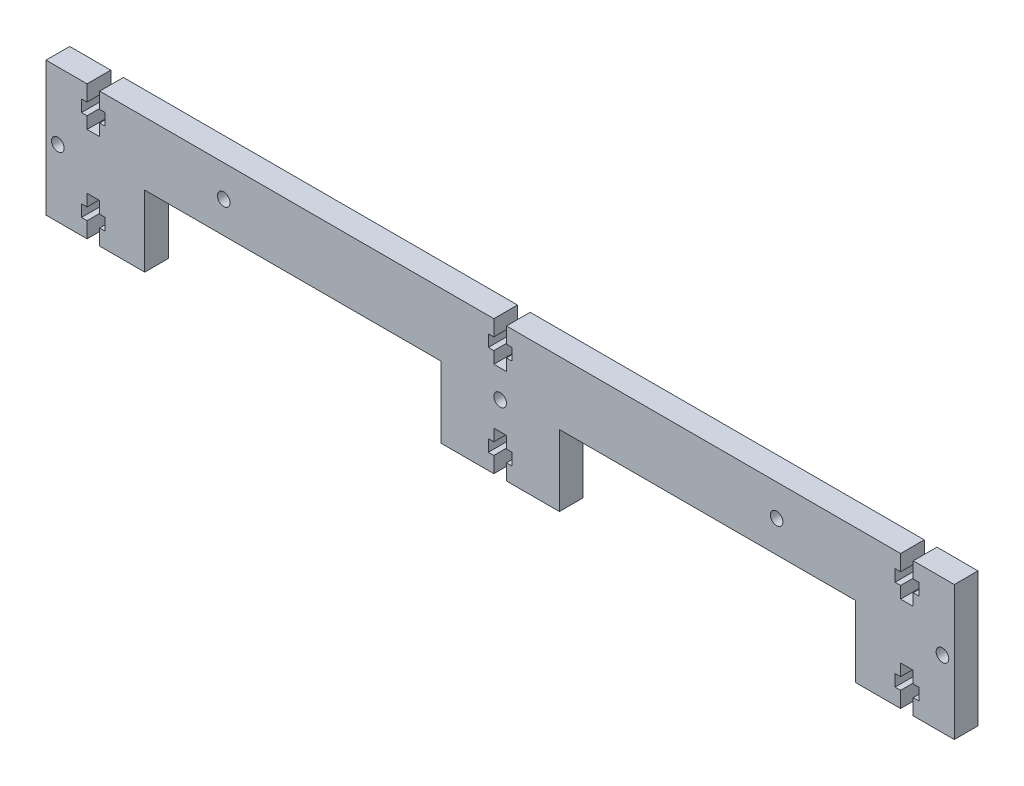
from build123d import *

# Parameters (mm, degrees)
ESBO_O1_R                = 1.6
RESSALTO_EXTRUS_O1_DEPTH = 6
ESBO_O2_R                = 1.6
ESBO_O2_W                = 75
ESBO_O2_H                = 18
CORTE_EXTRUS_O1_DEPTH    = 10


with BuildPart() as part:
    # Esboço1 → Ressalto-extrusão1 (new body)
    with BuildSketch(Plane.XY):
        Polygon((-115, 17), (-115, -17), (-104.6, -17), (-104.6, -13), (-106, -13), (-106, -10), (-104.6, -10), (-104.6, -7), (-101.4, -7), (-101.4, -10), (-100, -10), (-100, -13), (-101.4, -13), (-101.4, -17), (-1.6, -17), (-1.6, -13), (-3, -13), (-3, -10), (-1.6, -10), (-1.6, -7), (1.6, -7), (1.6, -10), (3, -10), (3, -13), (1.6, -13), (1.6, -17), (101.4, -17), (101.4, -13), (100, -13), (100, -10), (101.4, -10), (101.4, -7), (104.6, -7), (104.6, -10), (106, -10), (106, -13), (104.6, -13), (104.6, -17), (115, -17), (115, 17), (104.6, 17), (104.6, 13), (106, 13), (106, 10), (104.6, 10), (104.6, 7), (101.4, 7), (101.4, 10), (100, 10), (100, 13), (101.4, 13), (101.4, 17), (1.6, 17), (1.6, 13), (3, 13), (3, 10), (1.6, 10), (1.6, 7), (-1.6, 7), (-1.6, 10), (-3, 10), (-3, 13), (-1.6, 13), (-1.6, 17), (-101.4, 17), (-101.4, 13), (-100, 13), (-100, 10), (-101.4, 10), (-101.4, 7), (-104.6, 7), (-104.6, 10), (-106, 10), (-106, 13), (-104.6, 13), (-104.6, 17), align=None)
        with Locations((112, 0)):
            Circle(ESBO_O1_R, mode=Mode.SUBTRACT)
        Circle(ESBO_O1_R, mode=Mode.SUBTRACT)
        with Locations((-112, 0)):
            Circle(ESBO_O1_R, mode=Mode.SUBTRACT)
    extrude(amount=RESSALTO_EXTRUS_O1_DEPTH)

    # Esboço2 → Corte-extrusão1 (cut)
    with BuildSketch(Plane.XY.offset(6)):
        with Locations((70, 9)):
            Circle(ESBO_O2_R)
        with Locations((-70, 9)):
            Circle(ESBO_O2_R)
        with Locations((52.5, -8)):
            Rectangle(ESBO_O2_W, ESBO_O2_H)
        with Locations((-52.5, -8)):
            Rectangle(ESBO_O2_W, ESBO_O2_H)
    extrude(amount=-CORTE_EXTRUS_O1_DEPTH, mode=Mode.SUBTRACT)


solid = part.part
